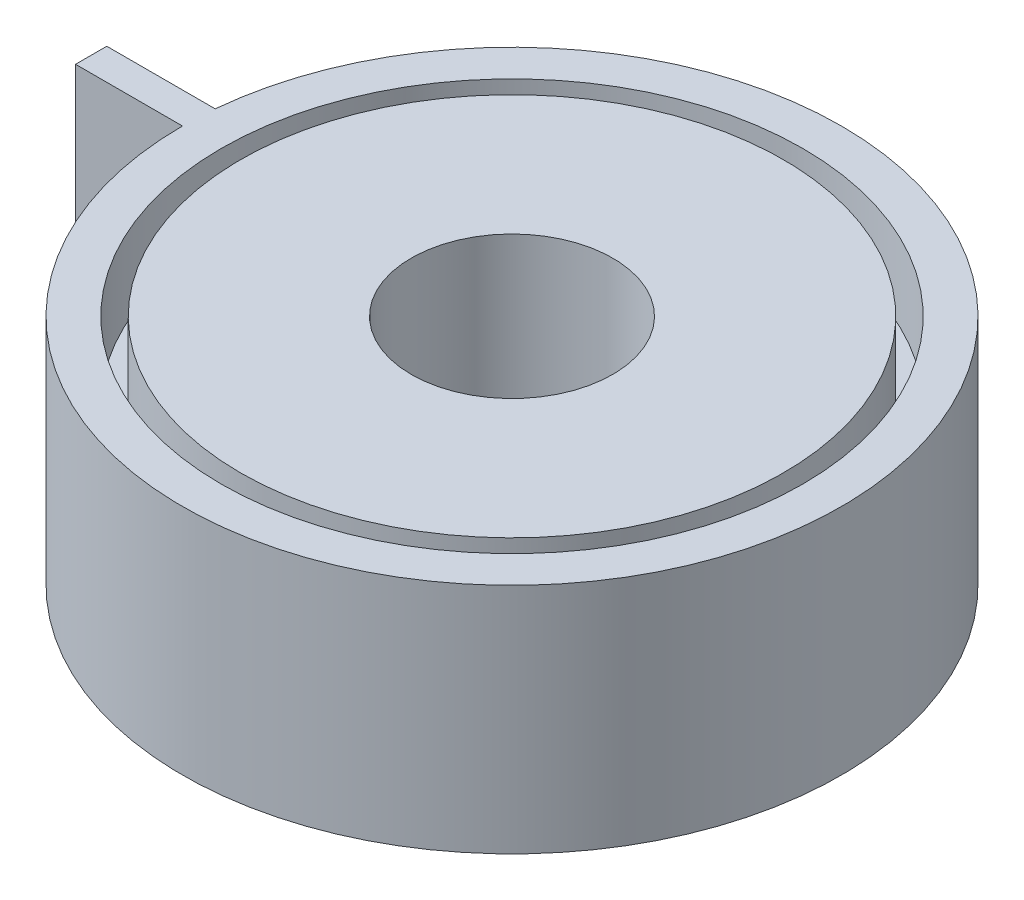
from build123d import *

# Parameters (mm, degrees)
SKETCH1_R           = 26
BOSS_EXTRUDE1_DEPTH = 60
SKETCH2_R           = 75
SKETCH2_R_2         = 70
CUT_EXTRUDE1_DEPTH  = 20
SKETCH3_R           = 75
SKETCH3_R_2         = 70
CUT_EXTRUDE2_DEPTH  = 20


with BuildPart() as part:
    # Sketch1 → Boss-Extrude1 (new body)
    with BuildSketch(Plane(origin=(0, 0, 0), x_dir=(1, 0, 0), z_dir=(0, 1, 0))):
        with BuildLine():
            Line((-85, 0), (-112.580048144, 0))
            Line((-112.580048144, 0), (-112.580048144, 8.059280082))
            Line((-112.580048144, 8.059280082), (-84.617066863, 8.059280082))
            ThreePointArc((-84.617066863, 8.059280082), (84.904212744, -4.034186201), (-85, 0))
        make_face()
        Circle(SKETCH1_R, mode=Mode.SUBTRACT)
    extrude(amount=BOSS_EXTRUDE1_DEPTH)

    # Sketch2 → Cut-Extrude1 (cut)
    with BuildSketch(Plane(origin=(0, 0, 0), x_dir=(-1, 0, 0), z_dir=(0, -1, 0))):
        Circle(SKETCH2_R)
        Circle(SKETCH2_R_2, mode=Mode.SUBTRACT)
    extrude(amount=-CUT_EXTRUDE1_DEPTH, mode=Mode.SUBTRACT)

    # Sketch3 → Cut-Extrude2 (cut)
    with BuildSketch(Plane(origin=(0, 60, 0), x_dir=(1, 0, 0), z_dir=(0, 1, 0))):
        Circle(SKETCH3_R)
        Circle(SKETCH3_R_2, mode=Mode.SUBTRACT)
    extrude(amount=-CUT_EXTRUDE2_DEPTH, mode=Mode.SUBTRACT)


solid = part.part
